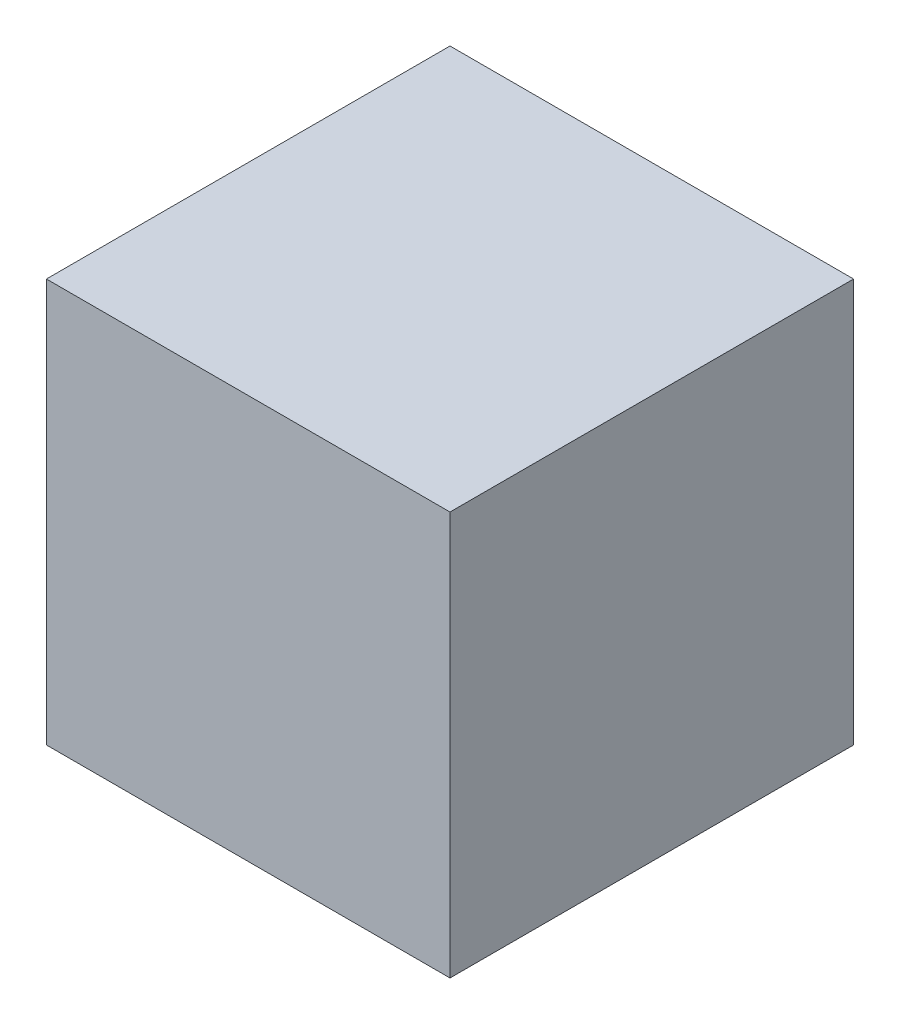
from build123d import *

# Parameters (mm, degrees)
CROQUIS1_W              = 60
CROQUIS1_H              = 60
SALIENTE_EXTRUIR1_DEPTH = 60


with BuildPart() as part:
    # Croquis1 → Saliente-Extruir1 (new body)
    with BuildSketch(Plane.XY):
        Rectangle(CROQUIS1_W, CROQUIS1_H)
    extrude(amount=SALIENTE_EXTRUIR1_DEPTH)


solid = part.part
